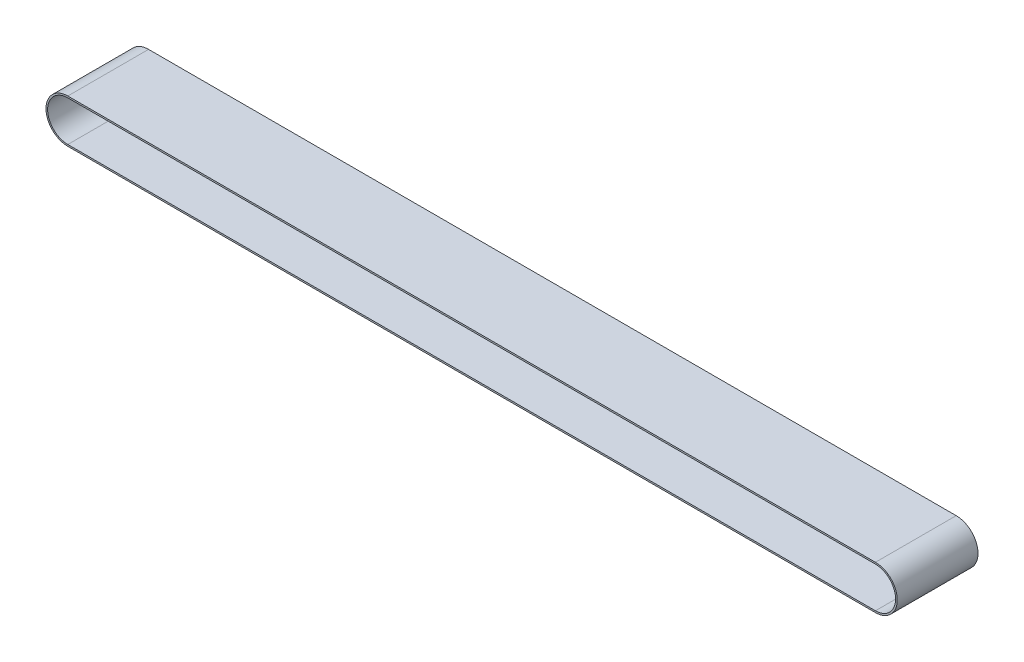
from build123d import *

# Parameters (mm, degrees)
ESTRUSIONE_SOTTILE1_DEPTH = 100


with BuildPart() as part:
    # Schizzo2 → Estrusione-Sottile1 (new body)
    with BuildSketch(Plane.XY):
        with BuildLine():
            Line((500, -27), (-500, -27))
            ThreePointArc((-500, -27), (-527, 0), (-500, 27))
            Line((-500, 27), (500, 27))
            ThreePointArc((500, 27), (527, 0), (500, -27))
        make_face()
        with BuildLine():
            Line((500, -25), (-500, -25))
            ThreePointArc((-500, -25), (-525, 0), (-500, 25))
            Line((-500, 25), (500, 25))
            ThreePointArc((500, 25), (525, 0), (500, -25))
        make_face(mode=Mode.SUBTRACT)
    extrude(amount=ESTRUSIONE_SOTTILE1_DEPTH)


solid = part.part
